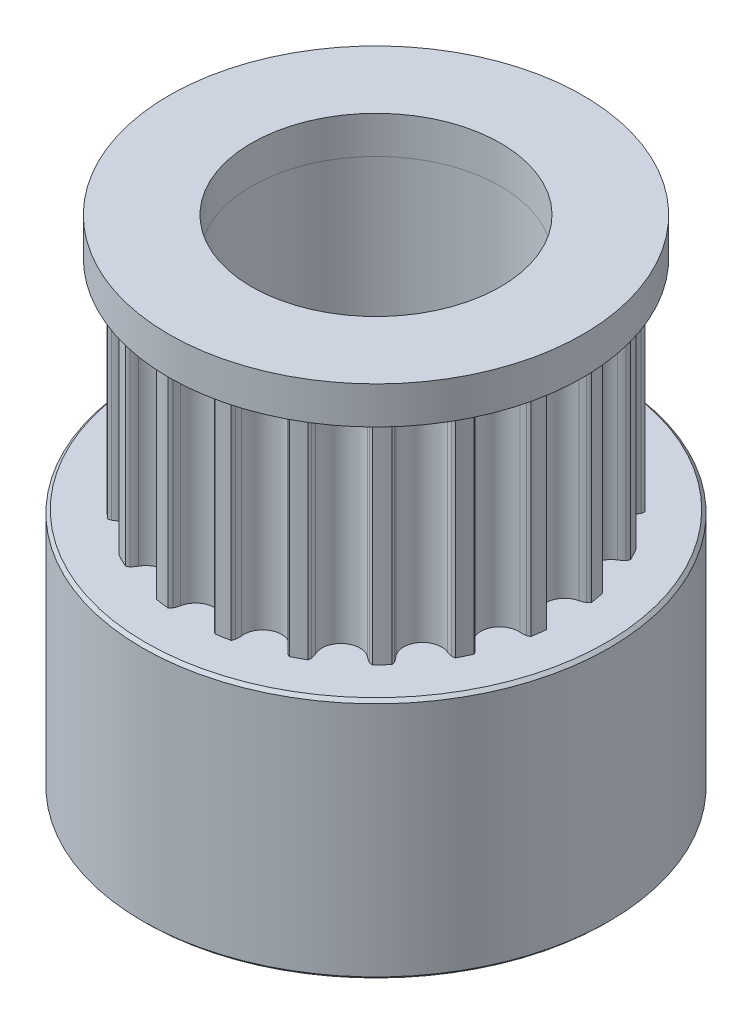
from build123d import *

# Parameters (mm, degrees)
P_IDAT_START            = 7.8
SKICA1_R                = 2.5
P_IDAT_VYSUNUT_M1_DEPTH = 7
SKICA2_R                = 3.5
SKICA2_R_2              = 2.5
P_IDAT_VYSUNUT_M2_DEPTH = 7.8
SKICA3_R                = 3.5
SKICA3_R_2              = 2.5
P_IDAT_VYSUNUT_M3_DEPTH = 1.2
SKICA5_R                = 7.5
SKICA5_R_2              = 3.5
P_IDAT_VYSUNUT_M4_DEPTH = 1.2
SKICA6_R                = 7.5
SKICA6_R_2              = 3.5
P_IDAT_VYSUNUT_M5_DEPTH = 7.8
ZKOSEN_1_SIZE           = 0.1
ZKOSEN_2_SIZE           = 0.1
ZKOSEN_3_SIZE           = 0.1
SKETCH7_R               = 4
CUT_EXTRUDE1_DEPTH      = 20
SKETCH8_OUTSIDE_W       = 22.314
SKETCH8_OUTSIDE_H       = 22.314
SKETCH8_OUTSIDE_R       = 6.65
CUT_EXTRUDE2_DEPTH      = 5
SKETCH19_R              = 1.5
CUT_EXTRUDE6_DEPTH      = 5
SKETCH20_R              = 1.5
CUT_EXTRUDE7_DEPTH      = 5


with BuildPart() as part:
    # Skica1 → Přidat vysunutím1 (new body)
    with BuildSketch(Plane(origin=(0, 0, 0), x_dir=(1, 0, 0), z_dir=(0, 1, 0)).offset(P_IDAT_START)):
        with BuildLine():
            ThreePointArc((-5.730143195, 1.098270155), (-5.09645097, 1.530497044), (-5.387174672, 2.240331989))
            ThreePointArc((-5.387174672, 2.240331989), (-5.468060657, 2.292707421), (-5.540463547, 2.356296335))
            ThreePointArc((-5.540463547, 2.356296335), (-5.573874331, 2.399596558), (-5.596043873, 2.44959357))
            ThreePointArc((-5.596043873, 2.44959357), (-5.50369925, 2.650567912), (-5.404139771, 2.848067596))
            ThreePointArc((-5.404139771, 2.848067596), (-5.351227535, 2.86190541), (-5.296542742, 2.862779021))
            ThreePointArc((-5.296542742, 2.862779021), (-5.201685094, 2.845815675), (-5.110305882, 2.815228615))
            ThreePointArc((-5.110305882, 2.815228615), (-4.374063308, 3.030479148), (-4.431206919, 3.795410862))
            ThreePointArc((-4.431206919, 3.795410862), (-4.491949163, 3.870218002), (-4.541158349, 3.953068377))
            ThreePointArc((-4.541158349, 3.953068377), (-4.559553388, 4.004573836), (-4.565187949, 4.058974585))
            ThreePointArc((-4.565187949, 4.058974585), (-4.415258506, 4.221576484), (-4.259541056, 4.378644275))
            ThreePointArc((-4.259541056, 4.378644275), (-4.204942409, 4.375454038), (-4.15266412, 4.359386362))
            ThreePointArc((-4.15266412, 4.359386362), (-4.067691098, 4.313940635), (-3.990236225, 4.256612884))
            ThreePointArc((-3.990236225, 4.256612884), (-3.223511854, 4.233816838), (-3.041481758, 4.978968476))
            ThreePointArc((-3.041481758, 4.978968476), (-3.076134388, 5.06888468), (-3.097332931, 5.162886543))
            ThreePointArc((-3.097332931, 5.162886543), (-3.09891159, 5.217555525), (-3.08745962, 5.271034888))
            ThreePointArc((-3.08745962, 5.271034888), (-2.894621497, 5.379347737), (-2.697988784, 5.480608745))
            ThreePointArc((-2.697988784, 5.480608745), (-2.647048223, 5.460702739), (-2.6022938, 5.429266591))
            ThreePointArc((-2.6022938, 5.429266591), (-2.535523156, 5.359787029), (-2.479574443, 5.281330225))
            ThreePointArc((-2.479574443, 5.281330225), (-1.7574206, 5.022719037), (-1.354035171, 5.675149965))
            ThreePointArc((-1.354035171, 5.675149965), (-1.359206146, 5.771373608), (-1.350318985, 5.867325402))
            ThreePointArc((-1.350318985, 5.867325402), (-1.334926735, 5.919806527), (-1.307509232, 5.967129569))
            ThreePointArc((-1.307509232, 5.967129569), (-1.090638767, 6.010550954), (-0.872338572, 6.046093045))
            ThreePointArc((-0.872338572, 6.046093045), (-0.830042514, 6.01141981), (-0.797192832, 5.967692379))
            ThreePointArc((-0.797192832, 5.967692379), (-0.755160541, 5.880980125), (-0.726194639, 5.789074167))
            ThreePointArc((-0.726194639, 5.789074167), (-0.119300773, 5.319962501), (0.465953812, 5.815808234))
            ThreePointArc((0.465953812, 5.815808234), (0.490770664, 5.908920276), (0.528873591, 5.997429571))
            ThreePointArc((0.528873591, 5.997429571), (0.55973005, 6.04258562), (0.600429269, 6.079120034))
            ThreePointArc((0.600429269, 6.079120034), (0.820103284, 6.053399565), (1.038702217, 6.019743632))
            ThreePointArc((1.038702217, 6.019743632), (1.06821354, 5.973697225), (1.085942924, 5.921958857))
            ThreePointArc((1.085942924, 5.921958857), (1.099122448, 5.826501911), (1.098270155, 5.730143195))
            ThreePointArc((1.098270155, 5.730143195), (1.530497044, 5.09645097), (2.240331989, 5.387174672))
            ThreePointArc((2.240331989, 5.387174672), (2.292707421, 5.468060657), (2.356296335, 5.540463547))
            ThreePointArc((2.356296335, 5.540463547), (2.399596558, 5.573874331), (2.44959357, 5.596043873))
            ThreePointArc((2.44959357, 5.596043873), (2.650567912, 5.50369925), (2.848067596, 5.404139771))
            ThreePointArc((2.848067596, 5.404139771), (2.86190541, 5.351227535), (2.862779021, 5.296542742))
            ThreePointArc((2.862779021, 5.296542742), (2.845815675, 5.201685094), (2.815228615, 5.110305882))
            ThreePointArc((2.815228615, 5.110305882), (3.030479148, 4.374063308), (3.795410862, 4.431206919))
            ThreePointArc((3.795410862, 4.431206919), (3.870218002, 4.491949163), (3.953068377, 4.541158349))
            ThreePointArc((3.953068377, 4.541158349), (4.004573836, 4.559553388), (4.058974585, 4.565187949))
            ThreePointArc((4.058974585, 4.565187949), (4.221576484, 4.415258506), (4.378644275, 4.259541056))
            ThreePointArc((4.378644275, 4.259541056), (4.375454038, 4.204942409), (4.359386362, 4.15266412))
            ThreePointArc((4.359386362, 4.15266412), (4.313940635, 4.067691098), (4.256612884, 3.990236225))
            ThreePointArc((4.256612884, 3.990236225), (4.233816838, 3.223511854), (4.978968476, 3.041481758))
            ThreePointArc((4.978968476, 3.041481758), (5.06888468, 3.076134388), (5.162886543, 3.097332931))
            ThreePointArc((5.162886543, 3.097332931), (5.217555525, 3.09891159), (5.271034888, 3.08745962))
            ThreePointArc((5.271034888, 3.08745962), (5.379347737, 2.894621497), (5.480608745, 2.697988784))
            ThreePointArc((5.480608745, 2.697988784), (5.460702739, 2.647048223), (5.429266591, 2.6022938))
            ThreePointArc((5.429266591, 2.6022938), (5.359787029, 2.535523156), (5.281330225, 2.479574443))
            ThreePointArc((5.281330225, 2.479574443), (5.022719037, 1.7574206), (5.675149965, 1.354035171))
            ThreePointArc((5.675149965, 1.354035171), (5.771373608, 1.359206146), (5.867325402, 1.350318985))
            ThreePointArc((5.867325402, 1.350318985), (5.919806527, 1.334926735), (5.967129569, 1.307509232))
            ThreePointArc((5.967129569, 1.307509232), (6.010550954, 1.090638767), (6.046093045, 0.872338572))
            ThreePointArc((6.046093045, 0.872338572), (6.01141981, 0.830042514), (5.967692379, 0.797192832))
            ThreePointArc((5.967692379, 0.797192832), (5.880980125, 0.755160541), (5.789074167, 0.726194639))
            ThreePointArc((5.789074167, 0.726194639), (5.319962501, 0.119300773), (5.815808234, -0.465953812))
            ThreePointArc((5.815808234, -0.465953812), (5.908920276, -0.490770664), (5.997429571, -0.528873591))
            ThreePointArc((5.997429571, -0.528873591), (6.04258562, -0.55973005), (6.079120034, -0.600429269))
            ThreePointArc((6.079120034, -0.600429269), (6.053399565, -0.820103284), (6.019743632, -1.038702217))
            ThreePointArc((6.019743632, -1.038702217), (5.973697225, -1.06821354), (5.921958857, -1.085942924))
            ThreePointArc((5.921958857, -1.085942924), (5.826501911, -1.099122448), (5.730143195, -1.098270155))
            ThreePointArc((5.730143195, -1.098270155), (5.09645097, -1.530497044), (5.387174672, -2.240331989))
            ThreePointArc((5.387174672, -2.240331989), (5.468060657, -2.292707421), (5.540463547, -2.356296335))
            ThreePointArc((5.540463547, -2.356296335), (5.573874331, -2.399596558), (5.596043873, -2.44959357))
            ThreePointArc((5.596043873, -2.44959357), (5.50369925, -2.650567911), (5.404139771, -2.848067596))
            ThreePointArc((5.404139771, -2.848067596), (5.351227535, -2.86190541), (5.296542742, -2.862779021))
            ThreePointArc((5.296542742, -2.862779021), (5.201685094, -2.845815675), (5.110305882, -2.815228615))
            ThreePointArc((5.110305882, -2.815228615), (4.374063308, -3.030479148), (4.431206919, -3.795410862))
            ThreePointArc((4.431206919, -3.795410862), (4.491949163, -3.870218002), (4.541158349, -3.953068377))
            ThreePointArc((4.541158349, -3.953068377), (4.559553388, -4.004573836), (4.565187949, -4.058974585))
            ThreePointArc((4.565187949, -4.058974585), (4.415258506, -4.221576484), (4.259541056, -4.378644275))
            ThreePointArc((4.259541056, -4.378644275), (4.204942409, -4.375454038), (4.15266412, -4.359386362))
            ThreePointArc((4.15266412, -4.359386362), (4.067691098, -4.313940635), (3.990236225, -4.256612884))
            ThreePointArc((3.990236225, -4.256612884), (3.223511854, -4.233816838), (3.041481758, -4.978968476))
            ThreePointArc((3.041481758, -4.978968476), (3.076134388, -5.06888468), (3.097332931, -5.162886543))
            ThreePointArc((3.097332931, -5.162886543), (3.09891159, -5.217555525), (3.08745962, -5.271034888))
            ThreePointArc((3.08745962, -5.271034888), (2.894621497, -5.379347737), (2.697988784, -5.480608745))
            ThreePointArc((2.697988784, -5.480608745), (2.647048223, -5.460702739), (2.6022938, -5.429266591))
            ThreePointArc((2.6022938, -5.429266591), (2.535523156, -5.359787029), (2.479574443, -5.281330225))
            ThreePointArc((2.479574443, -5.281330225), (1.7574206, -5.022719037), (1.354035171, -5.675149965))
            ThreePointArc((1.354035171, -5.675149965), (1.359206146, -5.771373608), (1.350318985, -5.867325402))
            ThreePointArc((1.350318985, -5.867325402), (1.334926735, -5.919806527), (1.307509232, -5.967129569))
            ThreePointArc((1.307509232, -5.967129569), (1.090638767, -6.010550954), (0.872338572, -6.046093045))
            ThreePointArc((0.872338572, -6.046093045), (0.830042514, -6.01141981), (0.797192832, -5.967692379))
            ThreePointArc((0.797192832, -5.967692379), (0.755160541, -5.880980125), (0.726194639, -5.789074167))
            ThreePointArc((0.726194639, -5.789074167), (0.119300773, -5.319962501), (-0.465953812, -5.815808234))
            ThreePointArc((-0.465953812, -5.815808234), (-0.490770664, -5.908920276), (-0.528873591, -5.997429571))
            ThreePointArc((-0.528873591, -5.997429571), (-0.55973005, -6.04258562), (-0.600429269, -6.079120034))
            ThreePointArc((-0.600429269, -6.079120034), (-0.820103284, -6.053399565), (-1.038702217, -6.019743632))
            ThreePointArc((-1.038702217, -6.019743632), (-1.06821354, -5.973697225), (-1.085942924, -5.921958857))
            ThreePointArc((-1.085942924, -5.921958857), (-1.099122448, -5.826501911), (-1.098270155, -5.730143195))
            ThreePointArc((-1.098270155, -5.730143195), (-1.530497044, -5.09645097), (-2.240331989, -5.387174672))
            ThreePointArc((-2.240331989, -5.387174672), (-2.292707421, -5.468060657), (-2.356296335, -5.540463547))
            ThreePointArc((-2.356296335, -5.540463547), (-2.399596558, -5.573874331), (-2.44959357, -5.596043873))
            ThreePointArc((-2.44959357, -5.596043873), (-2.650567912, -5.50369925), (-2.848067596, -5.404139771))
            ThreePointArc((-2.848067596, -5.404139771), (-2.86190541, -5.351227535), (-2.862779021, -5.296542742))
            ThreePointArc((-2.862779021, -5.296542742), (-2.845815675, -5.201685094), (-2.815228615, -5.110305882))
            ThreePointArc((-2.815228615, -5.110305882), (-3.030479148, -4.374063308), (-3.795410862, -4.431206919))
            ThreePointArc((-3.795410862, -4.431206919), (-3.870218002, -4.491949163), (-3.953068377, -4.541158349))
            ThreePointArc((-3.953068377, -4.541158349), (-4.004573836, -4.559553388), (-4.058974585, -4.565187949))
            ThreePointArc((-4.058974585, -4.565187949), (-4.221576484, -4.415258506), (-4.378644275, -4.259541056))
            ThreePointArc((-4.378644275, -4.259541056), (-4.375454038, -4.204942409), (-4.359386362, -4.15266412))
            ThreePointArc((-4.359386362, -4.15266412), (-4.313940635, -4.067691098), (-4.256612884, -3.990236225))
            ThreePointArc((-4.256612884, -3.990236225), (-4.233816838, -3.223511854), (-4.978968476, -3.041481758))
            ThreePointArc((-4.978968476, -3.041481758), (-5.06888468, -3.076134388), (-5.162886543, -3.097332931))
            ThreePointArc((-5.162886543, -3.097332931), (-5.217555525, -3.09891159), (-5.271034888, -3.08745962))
            ThreePointArc((-5.271034888, -3.08745962), (-5.379347737, -2.894621497), (-5.480608745, -2.697988784))
            ThreePointArc((-5.480608745, -2.697988784), (-5.460702739, -2.647048223), (-5.429266591, -2.6022938))
            ThreePointArc((-5.429266591, -2.6022938), (-5.359787029, -2.535523156), (-5.281330225, -2.479574443))
            ThreePointArc((-5.281330225, -2.479574443), (-5.022719037, -1.7574206), (-5.675149965, -1.354035171))
            ThreePointArc((-5.675149965, -1.354035171), (-5.771373608, -1.359206146), (-5.867325402, -1.350318985))
            ThreePointArc((-5.867325402, -1.350318985), (-5.919806527, -1.334926735), (-5.967129569, -1.307509232))
            ThreePointArc((-5.967129569, -1.307509232), (-6.010550954, -1.090638767), (-6.046093045, -0.872338572))
            ThreePointArc((-6.046093045, -0.872338572), (-6.01141981, -0.830042514), (-5.967692379, -0.797192832))
            ThreePointArc((-5.967692379, -0.797192832), (-5.880980125, -0.755160541), (-5.789074167, -0.726194639))
            ThreePointArc((-5.789074167, -0.726194639), (-5.319962501, -0.119300773), (-5.815808234, 0.465953812))
            ThreePointArc((-5.815808234, 0.465953812), (-5.908920276, 0.490770664), (-5.997429571, 0.528873591))
            ThreePointArc((-5.997429571, 0.528873591), (-6.04258562, 0.55973005), (-6.079120034, 0.600429269))
            ThreePointArc((-6.079120034, 0.600429269), (-6.053399565, 0.820103284), (-6.019743632, 1.038702217))
            ThreePointArc((-6.019743632, 1.038702217), (-5.973697225, 1.06821354), (-5.921958857, 1.085942924))
            ThreePointArc((-5.921958857, 1.085942924), (-5.826501911, 1.099122448), (-5.730143195, 1.098270155))
        make_face()
        Circle(SKICA1_R, mode=Mode.SUBTRACT)
    extrude(amount=P_IDAT_VYSUNUT_M1_DEPTH)

    # Skica2 → Přidat vysunutím2 (add)
    with BuildSketch(Plane.XZ.offset(-7.8)):
        Circle(SKICA2_R)
        Circle(SKICA2_R_2, mode=Mode.SUBTRACT)
    extrude(amount=P_IDAT_VYSUNUT_M2_DEPTH)

    # Skica3 → Přidat vysunutím3 (add)
    with BuildSketch(Plane(origin=(0, 14.8, 0), x_dir=(1, 0, 0), z_dir=(0, 1, 0))):
        Circle(SKICA3_R)
        Circle(SKICA3_R_2, mode=Mode.SUBTRACT)
    extrude(amount=P_IDAT_VYSUNUT_M3_DEPTH)

    # Zkosení2
    zkosen_2_edges = [part.edges().sort_by_distance(p)[0] for p in [
        (-2.5, 0, 0),
        (-2.5, 16, 0),
    ]]
    chamfer(zkosen_2_edges, length=ZKOSEN_2_SIZE)


with BuildPart() as body_2:
    # Skica5 → Přidat vysunutím4 (new body)
    with BuildSketch(Plane(origin=(0, 16, 0), x_dir=(1, 0, 0), z_dir=(0, 1, 0))):
        Circle(SKICA5_R)
        Circle(SKICA5_R_2, mode=Mode.SUBTRACT)
    extrude(amount=-P_IDAT_VYSUNUT_M4_DEPTH)

    # Zkosení1
    zkosen_1_edges = [body_2.edges().sort_by_distance(p)[0] for p in [
        (-7.5, 16, 0),
        (-7.5, 14.8, 0),
    ]]
    chamfer(zkosen_1_edges, length=ZKOSEN_1_SIZE)


with BuildPart() as body_3:
    # Skica6 → Přidat vysunutím5 (new body)
    with BuildSketch(Plane.XZ):
        Circle(SKICA6_R)
        Circle(SKICA6_R_2, mode=Mode.SUBTRACT)
    extrude(amount=-P_IDAT_VYSUNUT_M5_DEPTH)

    # Zkosení3
    zkosen_3_edges = [body_3.edges().sort_by_distance(p)[0] for p in [
        (-7.5, 0, 0),
        (-7.5, 7.8, 0),
    ]]
    chamfer(zkosen_3_edges, length=ZKOSEN_3_SIZE)


with BuildPart() as cut_extrude1_tool:
    # Sketch7 → Cut-Extrude1 (new body)
    with BuildSketch(Plane.XZ):
        Circle(SKETCH7_R)
    extrude(amount=-CUT_EXTRUDE1_DEPTH)


with BuildPart() as part_1:
    add(part.part)

    # Cut-Extrude1: cut by cut_extrude1_tool
    add(cut_extrude1_tool.part, mode=Mode.SUBTRACT)


with BuildPart() as body_2_1:
    add(body_2.part)

    # Cut-Extrude1: cut by cut_extrude1_tool
    add(cut_extrude1_tool.part, mode=Mode.SUBTRACT)

    # Sketch8 outside → Cut-Extrude2 (cut)
    with BuildSketch(Plane(origin=(0, 16, 0), x_dir=(1, 0, 0), z_dir=(0, 1, 0))):
        Rectangle(SKETCH8_OUTSIDE_W, SKETCH8_OUTSIDE_H)
        Circle(SKETCH8_OUTSIDE_R, mode=Mode.SUBTRACT)
    extrude(amount=-CUT_EXTRUDE2_DEPTH, mode=Mode.SUBTRACT)


with BuildPart() as body_3_1:
    add(body_3.part)

    # Cut-Extrude1: cut by cut_extrude1_tool
    add(cut_extrude1_tool.part, mode=Mode.SUBTRACT)

    # Sketch19 → Cut-Extrude6 (cut)
    with BuildSketch(Plane(origin=(0, 0, -7.5), x_dir=(-1, 0, 0), z_dir=(0, 0, -1))):
        with Locations((0, 3.9)):
            Circle(SKETCH19_R)
    extrude(amount=-CUT_EXTRUDE6_DEPTH, mode=Mode.SUBTRACT)

    # Sketch20 → Cut-Extrude7 (cut)
    with BuildSketch(Plane.ZY.offset(7.5)):
        with Locations((0, 3.9)):
            Circle(SKETCH20_R)
    extrude(amount=-CUT_EXTRUDE7_DEPTH, mode=Mode.SUBTRACT)


solid = Compound([part_1.part, body_2_1.part, body_3_1.part])
